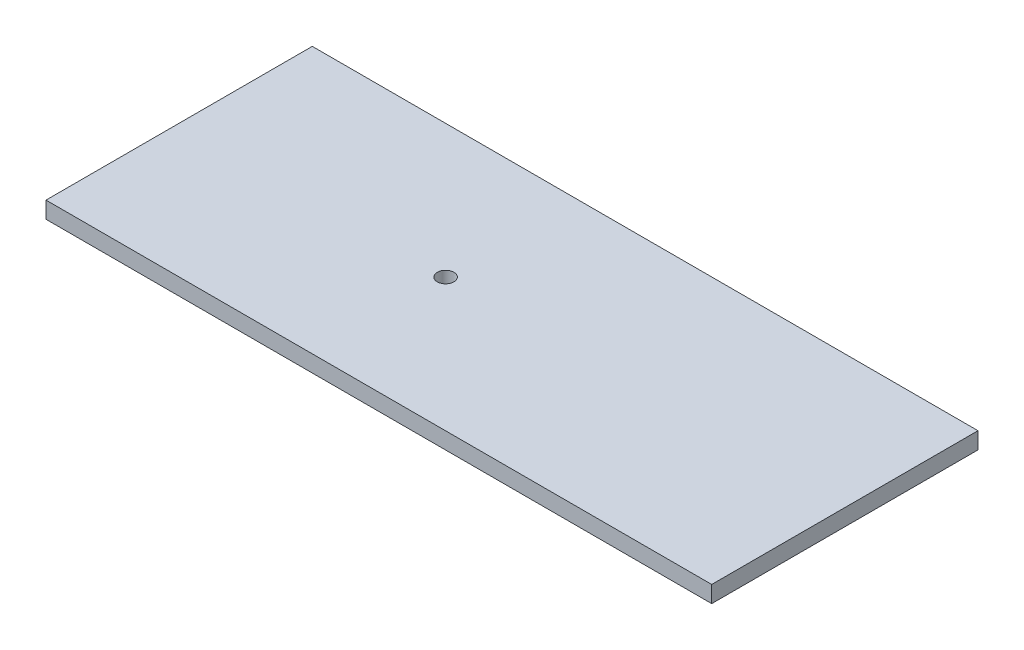
from build123d import *

# Parameters (mm, degrees)
SKETCH1_W           = 1524
SKETCH1_H           = 609.6
BOSS_EXTRUDE1_DEPTH = 38.1
SKETCH2_R           = 19.05
CUT_EXTRUDE1_DEPTH  = 39.1


with BuildPart() as part:
    # Sketch1 → Boss-Extrude1 (new body)
    with BuildSketch(Plane(origin=(0, 0, 0), x_dir=(1, 0, 0), z_dir=(0, 1, 0))):
        Rectangle(SKETCH1_W, SKETCH1_H)
    extrude(amount=-BOSS_EXTRUDE1_DEPTH)

    # Sketch2 → Cut-Extrude1 (cut, through all)
    with BuildSketch(Plane(origin=(0, 0, 0), x_dir=(1, 0, 0), z_dir=(0, 1, 0))):
        with Locations((-152, 0)):
            Circle(SKETCH2_R)
    extrude(amount=-CUT_EXTRUDE1_DEPTH, mode=Mode.SUBTRACT)


solid = part.part
